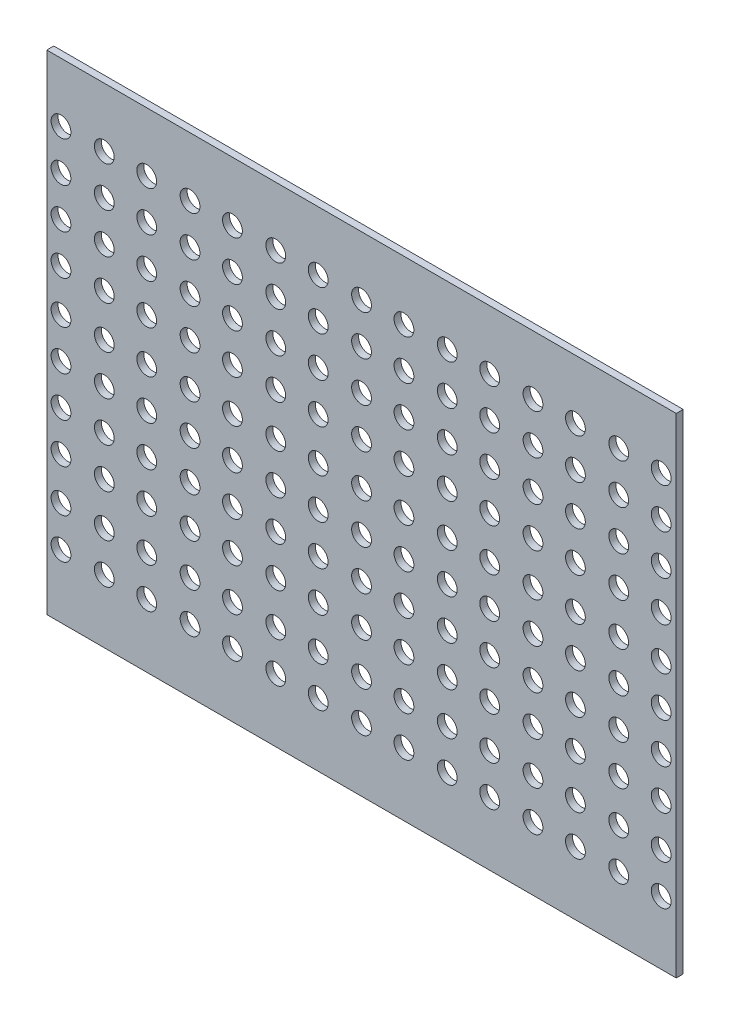
from build123d import *

# Parameters (mm, degrees)
BOSS_EXTRUDE1_DEPTH = 3.175
SKETCH2_R           = 4.5
CUT_EXTRUDE1_DEPTH  = 3.175
LPATTERN1_COUNT     = 8
LPATTERN1_PITCH     = 38.999999978


with BuildPart() as part:
    # Sketch1 → Boss-Extrude1 (new body)
    with BuildSketch(Plane.XY):
        Polygon((-26.150000016, -197), (-26.150000016, -206.525), (260.150000016, -206.525), (260.150000016, -197), (260.150000016, 15.875), (-26.150000016, 15.875), align=None)
    extrude(amount=BOSS_EXTRUDE1_DEPTH)

    # Sketch2 → Cut-Extrude1 (cut)
    with BuildSketch(Plane.XY.offset(3.175)):
        with Locations((253.3, -11)):
            Circle(SKETCH2_R)
        with Locations((234, -11)):
            Circle(SKETCH2_R)
        with Locations((253.3, -85.2)):
            Circle(SKETCH2_R)
        with Locations((234, -85.2)):
            Circle(SKETCH2_R)
        with Locations((253.3, -29.3)):
            Circle(SKETCH2_R)
        with Locations((234, -29.3)):
            Circle(SKETCH2_R)
        with Locations((253.3, -47.6)):
            Circle(SKETCH2_R)
        with Locations((234, -47.6)):
            Circle(SKETCH2_R)
        with Locations((253.3, -65.9)):
            Circle(SKETCH2_R)
        with Locations((234, -65.9)):
            Circle(SKETCH2_R)
        with Locations((253.3, -103.5)):
            Circle(SKETCH2_R)
        with Locations((234, -103.5)):
            Circle(SKETCH2_R)
        with Locations((253.3, -121.8)):
            Circle(SKETCH2_R)
        with Locations((234, -121.8)):
            Circle(SKETCH2_R)
        with Locations((253.3, -140.1)):
            Circle(SKETCH2_R)
        with Locations((234, -140.1)):
            Circle(SKETCH2_R)
        with Locations((253.3, -159.4)):
            Circle(SKETCH2_R)
        with Locations((234, -159.4)):
            Circle(SKETCH2_R)
        with Locations((253.3, -177.7)):
            Circle(SKETCH2_R)
        with Locations((234, -177.7)):
            Circle(SKETCH2_R)
    cut_extrude1 = extrude(amount=-CUT_EXTRUDE1_DEPTH, mode=Mode.SUBTRACT)

    # LPattern1: Cut-Extrude1 ×8
    with Locations(*[(-i * LPATTERN1_PITCH, 0, 0) for i in range(1, LPATTERN1_COUNT)]):
        add(cut_extrude1, mode=Mode.SUBTRACT)


solid = part.part
